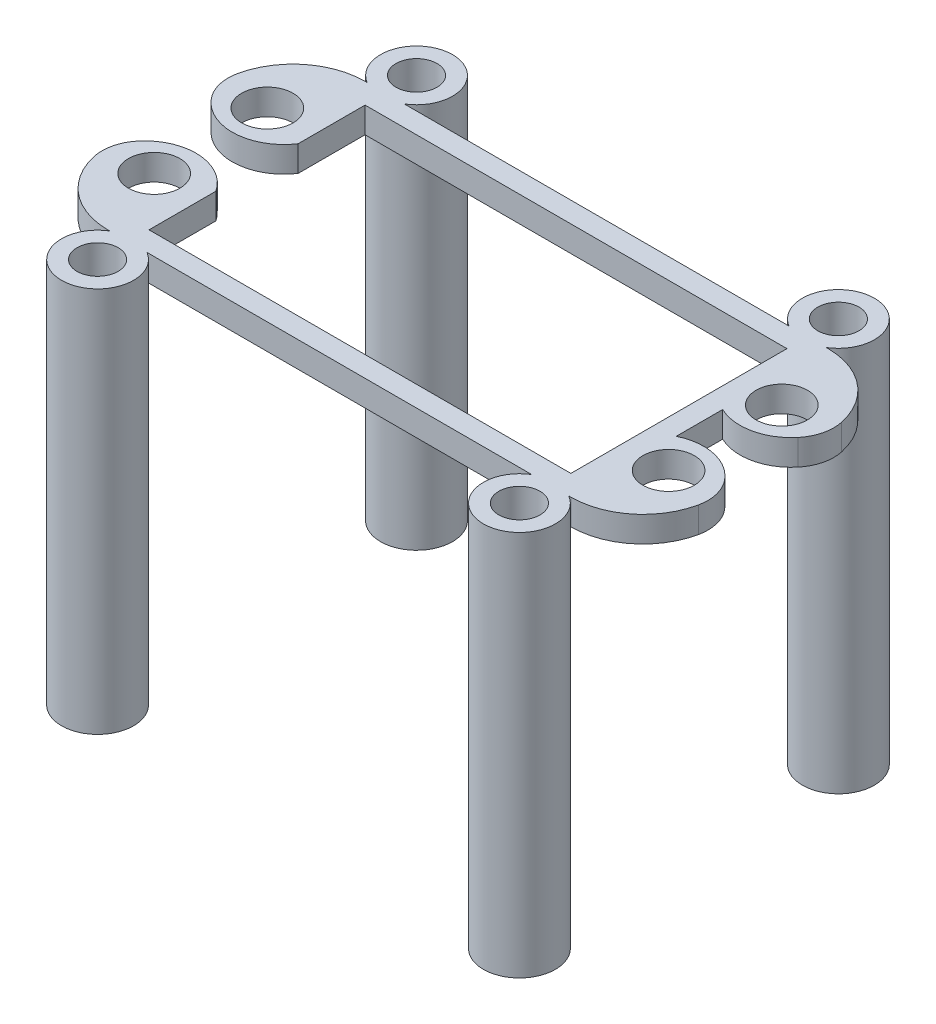
from build123d import *

# Parameters (mm, degrees)
SKETCH1_R                = 2.5
BOSS_EXTRUDE1_DEPTH      = 2.5
SKETCH4_R                = 3.5
SKETCH4_R_2              = 2
BOSS_EXTRUDE2_DEPTH      = 2.5
BOSS_EXTRUDE2_DEPTH_BACK = 35


with BuildPart() as part:
    # Sketch1 → Boss-Extrude1 (new body)
    with BuildSketch(Plane(origin=(0, 0, 0), x_dir=(1, 0, 0), z_dir=(0, 1, 0))):
        with BuildLine():
            Line((20.5, 10.5), (-20.5, 10.5))
            Line((-20.5, 10.5), (-20.5, 4))
            ThreePointArc((-20.5, 4), (-24.40287122, 1.76806345), (-28.520566145, 3.573204173))
            ThreePointArc((-28.520566145, 3.573204173), (-29.324072849, 5.171652721), (-29.350396575, 6.960498116))
            ThreePointArc((-29.350396575, 6.960498116), (-26.904940816, 10.941842627), (-22.5, 12.5))
            Line((-22.5, 12.5), (22.5, 12.5))
            ThreePointArc((22.5, 12.5), (26.904940816, 10.941842627), (29.350396575, 6.960498116))
            ThreePointArc((29.350396575, 6.960498116), (29.324072849, 5.171652721), (28.520566145, 3.573204173))
            ThreePointArc((28.520566145, 3.573204173), (25.737402548, 1.876578025), (22.5, 2.2557411))
            Line((22.5, 2.2557411), (22.5, -2.2557411))
            ThreePointArc((22.5, -2.2557411), (25.737402548, -1.876578025), (28.520566145, -3.573204173))
            ThreePointArc((28.520566145, -3.573204173), (29.324072849, -5.171652721), (29.350396575, -6.960498116))
            ThreePointArc((29.350396575, -6.960498116), (26.904940816, -10.941842627), (22.5, -12.5))
            Line((22.5, -12.5), (-22.5, -12.5))
            ThreePointArc((-22.5, -12.5), (-26.904940816, -10.941842627), (-29.350396575, -6.960498116))
            ThreePointArc((-29.350396575, -6.960498116), (-29.324072849, -5.171652721), (-28.520566145, -3.573204173))
            ThreePointArc((-28.520566145, -3.573204173), (-24.40287122, -1.76806345), (-20.5, -4))
            Line((-20.5, -4), (-20.5, -10.5))
            Line((-20.5, -10.5), (20.5, -10.5))
            Line((20.5, -10.5), (20.5, 10.5))
        make_face()
        with Locations((-25, 5.5)):
            Circle(SKETCH1_R, mode=Mode.SUBTRACT)
        with Locations((-25, -5.5)):
            Circle(SKETCH1_R, mode=Mode.SUBTRACT)
        with Locations((25, -5.5)):
            Circle(SKETCH1_R, mode=Mode.SUBTRACT)
        with Locations((25, 5.5)):
            Circle(SKETCH1_R, mode=Mode.SUBTRACT)
    extrude(amount=BOSS_EXTRUDE1_DEPTH)

    # Sketch4 → Boss-Extrude2 (add, two sides)
    with BuildSketch(Plane(origin=(0, 0, 0), x_dir=(1, 0, 0), z_dir=(0, 1, 0))) as boss_extrude2_sk:
        with Locations((-20.5, 15.5)):
            Circle(SKETCH4_R)
        with Locations((-20.5, 15.5)):
            Circle(SKETCH4_R_2, mode=Mode.SUBTRACT)
        with Locations((20.5, 15.5)):
            Circle(SKETCH4_R)
        with Locations((20.5, 15.5)):
            Circle(SKETCH4_R_2, mode=Mode.SUBTRACT)
        with Locations((-20.5, -15.5)):
            Circle(SKETCH4_R)
        with Locations((-20.5, -15.5)):
            Circle(SKETCH4_R_2, mode=Mode.SUBTRACT)
        with Locations((20.5, -15.5)):
            Circle(SKETCH4_R)
        with Locations((20.5, -15.5)):
            Circle(SKETCH4_R_2, mode=Mode.SUBTRACT)
    extrude(amount=BOSS_EXTRUDE2_DEPTH)
    extrude(boss_extrude2_sk.sketch, amount=-BOSS_EXTRUDE2_DEPTH_BACK)


solid = part.part
